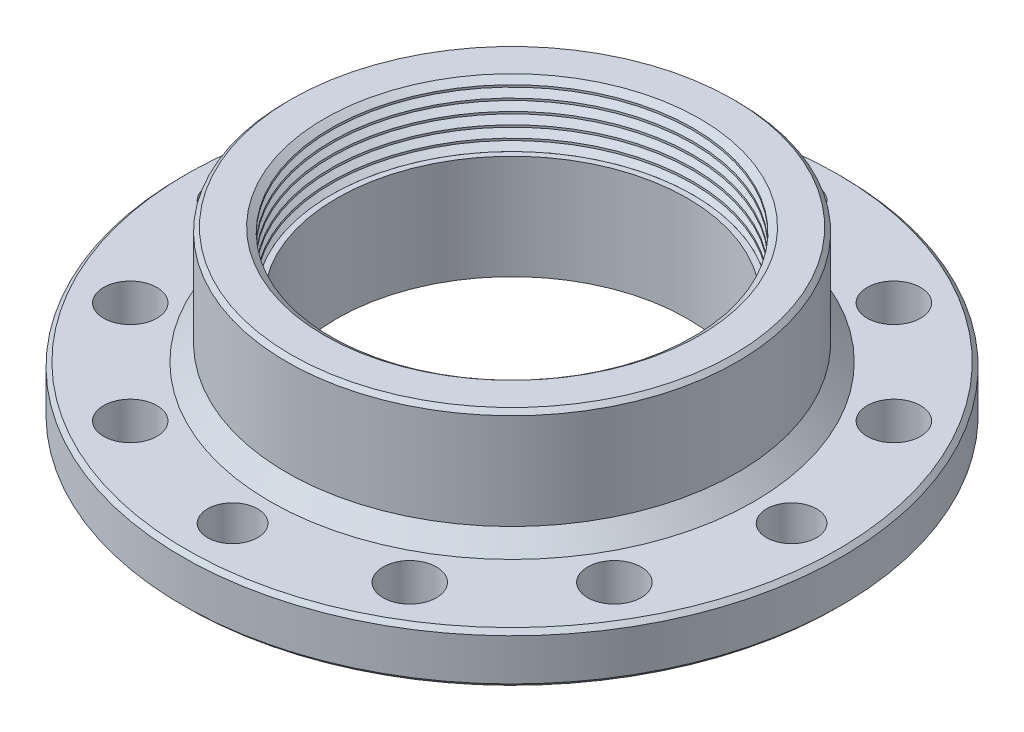
from build123d import *

# Parameters (mm, degrees)
CHAMFER_1_SIZE         = 2
CHAMFER_2_SIZE         = 0.5
HOLE_WIZARD_M61_D      = 6.4
SKETCH_2_R             = 3
CUT_EXTRUDE_1_DEPTH    = 7
SKETCH_4_R             = 21.688
CUT_EXTRUDE_2_DEPTH    = 7.5
PATTERN_LINEAR_1_COUNT = 6
PATTERN_LINEAR_1_PITCH = 1.386


with BuildPart() as part:
    # Эскиз1 → Повернуть1 (revolve)
    with BuildSketch(Plane.XY):
        Polygon((-39.5, 0), (-21, 0), (-21, 20), (-27, 20), (-27, 6), (-39.5, 6), align=None)
    revolve(axis=Axis((0, 0, 0), (0, 1, 0)))

    # Фаска1
    chamfer_1_edges = [part.edges().sort_by_distance(p)[0] for p in [
        (27, 6, 0),
    ]]
    chamfer(chamfer_1_edges, length=CHAMFER_1_SIZE)

    # Фаска2
    chamfer_2_edges = [part.edges().sort_by_distance(p)[0] for p in [
        (39.5, 6, 0),
        (27, 20, 0),
        (39.5, 0, 0),
    ]]
    chamfer(chamfer_2_edges, length=CHAMFER_2_SIZE)

    # Отверстие с зазором M61 (through all)
    with Locations(Plane(origin=(-16.75, 6, 29.011851027), x_dir=(0, 0, 1), z_dir=(0, 1, 0))):
        with Locations((0, 0), (-45.761851027, -12.261851027), (-58.023702054, 33.5), (-12.261851027, 45.761851027), (-12.261851027, -12.261851027), (-58.023702054, 0), (-45.761851027, 45.761851027), (0, 33.5)):
            Hole(HOLE_WIZARD_M61_D / 2)

    # Эскиз2 → Вытянуть1 (cut, through all)
    with BuildSketch(Plane(origin=(0, 6, 0), x_dir=(1, 0, 0), z_dir=(0, 1, 0))):
        with Locations((-33.5, 0)):
            Circle(SKETCH_2_R)
        with Locations((0, 33.5)):
            Circle(SKETCH_2_R)
        with Locations((33.5, 0)):
            Circle(SKETCH_2_R)
        with Locations((0, -33.5)):
            Circle(SKETCH_2_R)
    extrude(amount=-CUT_EXTRUDE_1_DEPTH, mode=Mode.SUBTRACT)

    # Эскиз6 → Вырез-Повернуть2 (revolve, cut)
    with BuildSketch(Plane(origin=(0, 6, 0), x_dir=(1, 0, 0), z_dir=(0, 1, 0))):
        with BuildLine():
            Line((-24.04163056, 24.04163056), (-23.334523779, 23.334523779))
            ThreePointArc((-23.334523779, 23.334523779), (-24.04163056, 23.334523779), (-24.04163056, 24.04163056))
        make_face()
    revolve(axis=Axis((0, 6, 0), (-0.707106781, 0, -0.707106781)), mode=Mode.SUBTRACT)

    # Эскиз4 → Вытянуть2 (cut)
    with BuildSketch(Plane(origin=(0, 20, 0), x_dir=(1, 0, 0), z_dir=(0, 1, 0))):
        Circle(SKETCH_4_R)
    extrude(amount=-CUT_EXTRUDE_2_DEPTH, mode=Mode.SUBTRACT)

    # Эскиз5 → Вырез-Повернуть1 (revolve, cut)
    with BuildSketch(Plane.XY):
        Polygon((-22.5, 20), (-21.688, 20.568568521), (-15, 20.568568521), (-15, 19.431431479), (-21.688, 19.431431479), align=None)
    cut_revolve_1 = revolve(axis=Axis((0, 0, 0), (0, 1, 0)), mode=Mode.SUBTRACT)

    # Линейный массив1: Вырез-Повернуть1 ×6
    with Locations(*[(0, -i * PATTERN_LINEAR_1_PITCH, 0) for i in range(1, PATTERN_LINEAR_1_COUNT)]):
        add(cut_revolve_1, mode=Mode.SUBTRACT)


solid = part.part
